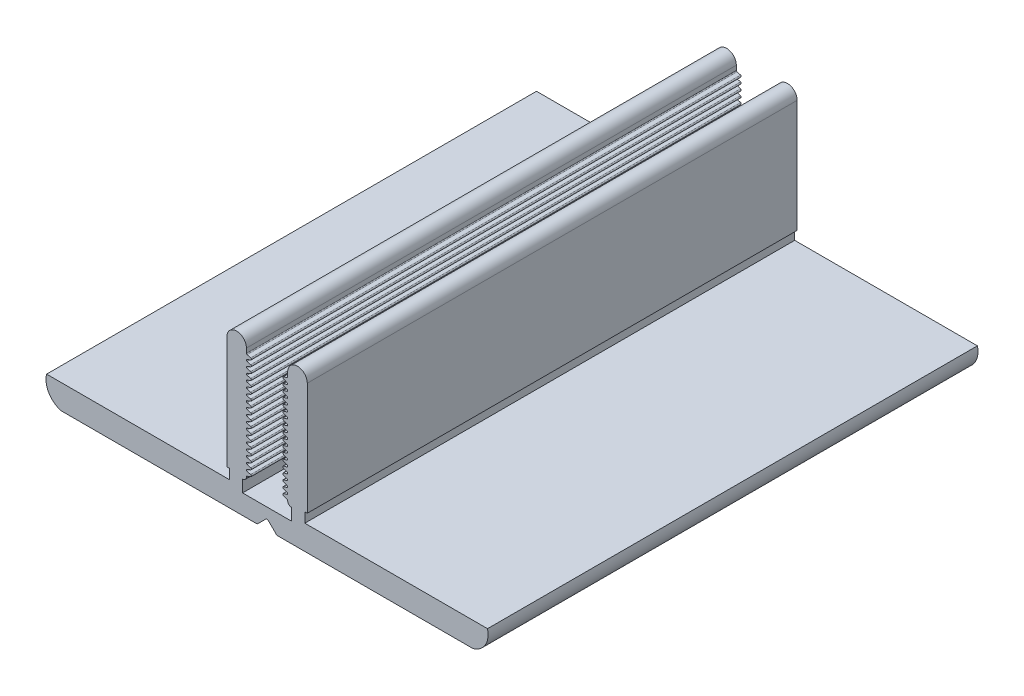
from build123d import *

# Parameters (mm, degrees)
EXTRUDE_2_DEPTH = 50


with BuildPart() as part:
    # Эскиз1 → Бобышка-Вытянуть2 (new body)
    with BuildSketch(Plane.XY):
        with BuildLine():
            Line((1.597541413, 2), (6.597450249, 2))
            Line((6.597450249, 2), (6.597450249, 3.219999818))
            ThreePointArc((6.597450249, 3.219999818), (6.318034469, 3.335737623), (6.202296664, 3.615153403))
            ThreePointArc((6.202296664, 3.615153403), (6.182496578, 3.671854652), (6.134631097, 3.708130963))
            Line((6.134631097, 3.708130963), (5.765036477, 3.845297648))
            ThreePointArc((5.765036477, 3.845297648), (5.699928757, 3.943484301), (5.77348091, 4.035515354))
            Line((5.77348091, 4.035515354), (6.128891922, 4.132594707))
            ThreePointArc((6.128891922, 4.132594707), (6.179848514, 4.165627509), (6.202296664, 4.222052865))
            ThreePointArc((6.202296664, 4.222052865), (6.182496578, 4.278754114), (6.134631097, 4.315030426))
            Line((6.134631097, 4.315030426), (5.765036477, 4.45219711))
            ThreePointArc((5.765036477, 4.45219711), (5.699928757, 4.550383763), (5.77348091, 4.642414817))
            Line((5.77348091, 4.642414817), (6.128891922, 4.739494169))
            ThreePointArc((6.128891922, 4.739494169), (6.179848514, 4.772526971), (6.202296664, 4.828952328))
            ThreePointArc((6.202296664, 4.828952328), (6.182496578, 4.885653577), (6.134631097, 4.921929888))
            Line((6.134631097, 4.921929888), (5.765036477, 5.059096573))
            ThreePointArc((5.765036477, 5.059096573), (5.699928757, 5.157283226), (5.77348091, 5.249314279))
            Line((5.77348091, 5.249314279), (6.128891922, 5.346393632))
            ThreePointArc((6.128891922, 5.346393632), (6.179848514, 5.379426434), (6.202296664, 5.43585179))
            ThreePointArc((6.202296664, 5.43585179), (6.182496578, 5.492553039), (6.134631097, 5.528829351))
            Line((6.134631097, 5.528829351), (5.765036477, 5.665996035))
            ThreePointArc((5.765036477, 5.665996035), (5.699928757, 5.764182688), (5.77348091, 5.856213742))
            Line((5.77348091, 5.856213742), (6.128891922, 5.953293094))
            ThreePointArc((6.128891922, 5.953293094), (6.179848514, 5.986325896), (6.202296664, 6.042751253))
            ThreePointArc((6.202296664, 6.042751253), (6.182496578, 6.099452502), (6.134631097, 6.135728813))
            Line((6.134631097, 6.135728813), (5.765036477, 6.272895498))
            ThreePointArc((5.765036477, 6.272895498), (5.699928757, 6.37108215), (5.77348091, 6.463113204))
            Line((5.77348091, 6.463113204), (6.128891922, 6.560192556))
            ThreePointArc((6.128891922, 6.560192556), (6.179848514, 6.593225359), (6.202296664, 6.649650715))
            ThreePointArc((6.202296664, 6.649650715), (6.182496578, 6.706351964), (6.134631097, 6.742628276))
            Line((6.134631097, 6.742628276), (5.765036477, 6.87979496))
            ThreePointArc((5.765036477, 6.87979496), (5.699928757, 6.977981613), (5.77348091, 7.070012667))
            Line((5.77348091, 7.070012667), (6.128891922, 7.167092019))
            ThreePointArc((6.128891922, 7.167092019), (6.179848514, 7.200124821), (6.202296664, 7.256550178))
            ThreePointArc((6.202296664, 7.256550178), (6.182496578, 7.313251427), (6.134631097, 7.349527738))
            Line((6.134631097, 7.349527738), (5.765036477, 7.486694423))
            ThreePointArc((5.765036477, 7.486694423), (5.699928757, 7.584881075), (5.77348091, 7.676912129))
            Line((5.77348091, 7.676912129), (6.128891922, 7.773991481))
            ThreePointArc((6.128891922, 7.773991481), (6.179848514, 7.807024284), (6.202296664, 7.86344964))
            ThreePointArc((6.202296664, 7.86344964), (6.182496578, 7.920150889), (6.134631097, 7.956427201))
            Line((6.134631097, 7.956427201), (5.765036477, 8.093593885))
            ThreePointArc((5.765036477, 8.093593885), (5.699928757, 8.191780538), (5.77348091, 8.283811592))
            Line((5.77348091, 8.283811592), (6.128891922, 8.380890944))
            ThreePointArc((6.128891922, 8.380890944), (6.179848514, 8.413923746), (6.202296664, 8.470349103))
            ThreePointArc((6.202296664, 8.470349103), (6.182496578, 8.527050352), (6.134631097, 8.563326663))
            Line((6.134631097, 8.563326663), (5.765036477, 8.700493348))
            ThreePointArc((5.765036477, 8.700493348), (5.699928757, 8.79868), (5.77348091, 8.890711054))
            Line((5.77348091, 8.890711054), (6.128891922, 8.987790406))
            ThreePointArc((6.128891922, 8.987790406), (6.179848514, 9.020823209), (6.202296664, 9.077248565))
            ThreePointArc((6.202296664, 9.077248565), (6.182496578, 9.133949814), (6.134631097, 9.170226126))
            Line((6.134631097, 9.170226126), (5.765036477, 9.30739281))
            ThreePointArc((5.765036477, 9.30739281), (5.699928757, 9.405579463), (5.77348091, 9.497610517))
            Line((5.77348091, 9.497610517), (6.128891922, 9.594689869))
            ThreePointArc((6.128891922, 9.594689869), (6.179848514, 9.627722671), (6.202296664, 9.684148028))
            ThreePointArc((6.202296664, 9.684148028), (6.182496578, 9.740849277), (6.134631097, 9.777125588))
            Line((6.134631097, 9.777125588), (5.765036477, 9.914292273))
            ThreePointArc((5.765036477, 9.914292273), (5.699928757, 10.012478925), (5.77348091, 10.104509979))
            Line((5.77348091, 10.104509979), (6.128891922, 10.201589331))
            ThreePointArc((6.128891922, 10.201589331), (6.179848514, 10.234622134), (6.202296664, 10.29104749))
            ThreePointArc((6.202296664, 10.29104749), (6.182496578, 10.347748739), (6.134631097, 10.384025051))
            Line((6.134631097, 10.384025051), (5.765036477, 10.521191735))
            ThreePointArc((5.765036477, 10.521191735), (5.699928757, 10.619378388), (5.77348091, 10.711409442))
            Line((5.77348091, 10.711409442), (6.128891922, 10.808488794))
            ThreePointArc((6.128891922, 10.808488794), (6.179848514, 10.841521596), (6.202296664, 10.897946953))
            ThreePointArc((6.202296664, 10.897946953), (6.182496578, 10.954648202), (6.134631097, 10.990924513))
            Line((6.134631097, 10.990924513), (5.765036477, 11.128091198))
            ThreePointArc((5.765036477, 11.128091198), (5.699928757, 11.22627785), (5.77348091, 11.318308904))
            Line((5.77348091, 11.318308904), (6.128891922, 11.415388256))
            ThreePointArc((6.128891922, 11.415388256), (6.179848514, 11.448421059), (6.202296664, 11.504846415))
            ThreePointArc((6.202296664, 11.504846415), (6.182496578, 11.561547664), (6.134631097, 11.597823976))
            Line((6.134631097, 11.597823976), (5.765036477, 11.73499066))
            ThreePointArc((5.765036477, 11.73499066), (5.699928757, 11.833177313), (5.77348091, 11.925208367))
            Line((5.77348091, 11.925208367), (6.128891922, 12.022287719))
            ThreePointArc((6.128891922, 12.022287719), (6.179848514, 12.055320521), (6.202296664, 12.111745877))
            ThreePointArc((6.202296664, 12.111745877), (6.182496578, 12.168447127), (6.134631097, 12.204723438))
            Line((6.134631097, 12.204723438), (5.765036477, 12.341890123))
            ThreePointArc((5.765036477, 12.341890123), (5.699928757, 12.440076775), (5.77348091, 12.532107829))
            Line((5.77348091, 12.532107829), (6.128891922, 12.629187181))
            ThreePointArc((6.128891922, 12.629187181), (6.179848514, 12.662219984), (6.202296664, 12.71864534))
            ThreePointArc((6.202296664, 12.71864534), (6.182496578, 12.775346589), (6.134631097, 12.811622901))
            Line((6.134631097, 12.811622901), (5.765036477, 12.948789585))
            ThreePointArc((5.765036477, 12.948789585), (5.699928757, 13.046976238), (5.77348091, 13.139007291))
            Line((5.77348091, 13.139007291), (6.128891922, 13.236086644))
            ThreePointArc((6.128891922, 13.236086644), (6.179848514, 13.269119446), (6.202296664, 13.325544802))
            ThreePointArc((6.202296664, 13.325544802), (6.182496578, 13.382246052), (6.134631097, 13.418522363))
            Line((6.134631097, 13.418522363), (5.765036477, 13.555689048))
            ThreePointArc((5.765036477, 13.555689048), (5.699928757, 13.6538757), (5.77348091, 13.745906754))
            Line((5.77348091, 13.745906754), (6.128891922, 13.842986106))
            ThreePointArc((6.128891922, 13.842986106), (6.179848514, 13.876018909), (6.202296664, 13.932444265))
            ThreePointArc((6.202296664, 13.932444265), (6.182496578, 13.989145514), (6.134631097, 14.025421826))
            Line((6.134631097, 14.025421826), (5.765036477, 14.16258851))
            ThreePointArc((5.765036477, 14.16258851), (5.699928757, 14.260775163), (5.77348091, 14.352806216))
            Line((5.77348091, 14.352806216), (6.128891922, 14.449885569))
            ThreePointArc((6.128891922, 14.449885569), (6.179848514, 14.482918371), (6.202296664, 14.539343727))
            Line((6.202296664, 14.539343727), (6.202296664, 15))
            ThreePointArc((6.202296664, 15), (7.202296664, 16), (8.202296664, 15))
            Line((8.202296664, 15), (8.202296664, 3.505592298))
            Line((8.202296664, 3.505592298), (7.952296664, 3.505592298))
            Line((7.952296664, 3.505592298), (7.952296664, 2.5))
            Line((7.952296664, 2.5), (10.76426584, 2.5))
            Line((10.76426584, 2.5), (26.597495831, 2.5))
            ThreePointArc((26.597495831, 2.5), (26.365262784, 0.939339828), (25.097495831, 0))
            Line((25.097495831, 0), (17.5, 0))
            Line((17.5, 0), (5.180338543, 0))
            ThreePointArc((5.180338543, 0), (5.103801857, 0.015224093), (5.038917187, 0.058578644))
            Line((5.038917187, 0.058578644), (4.238917187, 0.858578644))
            ThreePointArc((4.238917187, 0.858578644), (4.097495831, 0.917157288), (3.956074475, 0.858578644))
            Line((3.956074475, 0.858578644), (3.156074475, 0.058578644))
            ThreePointArc((3.156074475, 0.058578644), (3.091189805, 0.015224093), (3.014653118, 0))
            Line((3.014653118, 0), (-9.305008338, 0))
            Line((-9.305008338, 0), (-16.902504169, 0))
            ThreePointArc((-16.902504169, 0), (-18.170271122, 0.939339828), (-18.402504169, 2.5))
            Line((-18.402504169, 2.5), (0.242694998, 2.5))
            Line((0.242694998, 2.5), (0.242694998, 3.505592298))
            Line((0.242694998, 3.505592298), (-0.007305002, 3.505592298))
            Line((-0.007305002, 3.505592298), (-0.007305002, 15))
            ThreePointArc((-0.007305002, 15), (0.992694998, 16), (1.992694998, 15))
            Line((1.992694998, 15), (1.992694998, 14.539343727))
            ThreePointArc((1.992694998, 14.539343727), (2.015143148, 14.482918371), (2.06609974, 14.449885569))
            Line((2.06609974, 14.449885569), (2.421510752, 14.352806216))
            ThreePointArc((2.421510752, 14.352806216), (2.495062905, 14.260775163), (2.429955184, 14.16258851))
            Line((2.429955184, 14.16258851), (2.060360565, 14.025421826))
            ThreePointArc((2.060360565, 14.025421826), (2.012495084, 13.989145514), (1.992694998, 13.932444265))
            ThreePointArc((1.992694998, 13.932444265), (2.015143148, 13.876018909), (2.06609974, 13.842986106))
            Line((2.06609974, 13.842986106), (2.421510752, 13.745906754))
            ThreePointArc((2.421510752, 13.745906754), (2.495062905, 13.6538757), (2.429955184, 13.555689048))
            Line((2.429955184, 13.555689048), (2.060360565, 13.418522363))
            ThreePointArc((2.060360565, 13.418522363), (2.012495084, 13.382246052), (1.992694998, 13.325544802))
            ThreePointArc((1.992694998, 13.325544802), (2.015143148, 13.269119446), (2.06609974, 13.236086644))
            Line((2.06609974, 13.236086644), (2.421510752, 13.139007291))
            ThreePointArc((2.421510752, 13.139007291), (2.495062905, 13.046976238), (2.429955184, 12.948789585))
            Line((2.429955184, 12.948789585), (2.060360565, 12.811622901))
            ThreePointArc((2.060360565, 12.811622901), (2.012495084, 12.775346589), (1.992694998, 12.71864534))
            ThreePointArc((1.992694998, 12.71864534), (2.015143148, 12.662219984), (2.06609974, 12.629187181))
            Line((2.06609974, 12.629187181), (2.421510752, 12.532107829))
            ThreePointArc((2.421510752, 12.532107829), (2.495062905, 12.440076775), (2.429955184, 12.341890123))
            Line((2.429955184, 12.341890123), (2.060360565, 12.204723438))
            ThreePointArc((2.060360565, 12.204723438), (2.012495084, 12.168447127), (1.992694998, 12.111745877))
            ThreePointArc((1.992694998, 12.111745877), (2.015143148, 12.055320521), (2.06609974, 12.022287719))
            Line((2.06609974, 12.022287719), (2.421510752, 11.925208367))
            ThreePointArc((2.421510752, 11.925208367), (2.495062905, 11.833177313), (2.429955184, 11.73499066))
            Line((2.429955184, 11.73499066), (2.060360565, 11.597823976))
            ThreePointArc((2.060360565, 11.597823976), (2.012495084, 11.561547664), (1.992694998, 11.504846415))
            ThreePointArc((1.992694998, 11.504846415), (2.015143148, 11.448421059), (2.06609974, 11.415388256))
            Line((2.06609974, 11.415388256), (2.421510752, 11.318308904))
            ThreePointArc((2.421510752, 11.318308904), (2.495062905, 11.22627785), (2.429955184, 11.128091198))
            Line((2.429955184, 11.128091198), (2.060360565, 10.990924513))
            ThreePointArc((2.060360565, 10.990924513), (2.012495084, 10.954648202), (1.992694998, 10.897946953))
            ThreePointArc((1.992694998, 10.897946953), (2.015143148, 10.841521596), (2.06609974, 10.808488794))
            Line((2.06609974, 10.808488794), (2.421510752, 10.711409442))
            ThreePointArc((2.421510752, 10.711409442), (2.495062905, 10.619378388), (2.429955184, 10.521191735))
            Line((2.429955184, 10.521191735), (2.060360565, 10.384025051))
            ThreePointArc((2.060360565, 10.384025051), (2.012495084, 10.347748739), (1.992694998, 10.29104749))
            ThreePointArc((1.992694998, 10.29104749), (2.015143148, 10.234622134), (2.06609974, 10.201589331))
            Line((2.06609974, 10.201589331), (2.421510752, 10.104509979))
            ThreePointArc((2.421510752, 10.104509979), (2.495062905, 10.012478925), (2.429955184, 9.914292273))
            Line((2.429955184, 9.914292273), (2.060360565, 9.777125588))
            ThreePointArc((2.060360565, 9.777125588), (2.012495084, 9.740849277), (1.992694998, 9.684148028))
            ThreePointArc((1.992694998, 9.684148028), (2.015143148, 9.627722671), (2.06609974, 9.594689869))
            Line((2.06609974, 9.594689869), (2.421510752, 9.497610517))
            ThreePointArc((2.421510752, 9.497610517), (2.495062905, 9.405579463), (2.429955184, 9.30739281))
            Line((2.429955184, 9.30739281), (2.060360565, 9.170226126))
            ThreePointArc((2.060360565, 9.170226126), (2.012495084, 9.133949814), (1.992694998, 9.077248565))
            ThreePointArc((1.992694998, 9.077248565), (2.015143148, 9.020823209), (2.06609974, 8.987790406))
            Line((2.06609974, 8.987790406), (2.421510752, 8.890711054))
            ThreePointArc((2.421510752, 8.890711054), (2.495062905, 8.79868), (2.429955184, 8.700493348))
            Line((2.429955184, 8.700493348), (2.060360565, 8.563326663))
            ThreePointArc((2.060360565, 8.563326663), (2.012495084, 8.527050352), (1.992694998, 8.470349103))
            ThreePointArc((1.992694998, 8.470349103), (2.015143148, 8.413923746), (2.06609974, 8.380890944))
            Line((2.06609974, 8.380890944), (2.421510752, 8.283811592))
            ThreePointArc((2.421510752, 8.283811592), (2.495062905, 8.191780538), (2.429955184, 8.093593885))
            Line((2.429955184, 8.093593885), (2.060360565, 7.956427201))
            ThreePointArc((2.060360565, 7.956427201), (2.012495084, 7.920150889), (1.992694998, 7.86344964))
            ThreePointArc((1.992694998, 7.86344964), (2.015143148, 7.807024284), (2.06609974, 7.773991481))
            Line((2.06609974, 7.773991481), (2.421510752, 7.676912129))
            ThreePointArc((2.421510752, 7.676912129), (2.495062905, 7.584881075), (2.429955184, 7.486694423))
            Line((2.429955184, 7.486694423), (2.060360565, 7.349527738))
            ThreePointArc((2.060360565, 7.349527738), (2.012495084, 7.313251427), (1.992694998, 7.256550178))
            ThreePointArc((1.992694998, 7.256550178), (2.015143148, 7.200124821), (2.06609974, 7.167092019))
            Line((2.06609974, 7.167092019), (2.421510752, 7.070012667))
            ThreePointArc((2.421510752, 7.070012667), (2.495062905, 6.977981613), (2.429955184, 6.87979496))
            Line((2.429955184, 6.87979496), (2.060360565, 6.742628276))
            ThreePointArc((2.060360565, 6.742628276), (2.012495084, 6.706351964), (1.992694998, 6.649650715))
            ThreePointArc((1.992694998, 6.649650715), (2.015143148, 6.593225359), (2.06609974, 6.560192556))
            Line((2.06609974, 6.560192556), (2.421510752, 6.463113204))
            ThreePointArc((2.421510752, 6.463113204), (2.495062905, 6.37108215), (2.429955184, 6.272895498))
            Line((2.429955184, 6.272895498), (2.060360565, 6.135728813))
            ThreePointArc((2.060360565, 6.135728813), (2.012495084, 6.099452502), (1.992694998, 6.042751253))
            ThreePointArc((1.992694998, 6.042751253), (2.015143148, 5.986325896), (2.06609974, 5.953293094))
            Line((2.06609974, 5.953293094), (2.421510752, 5.856213742))
            ThreePointArc((2.421510752, 5.856213742), (2.495062905, 5.764182688), (2.429955184, 5.665996035))
            Line((2.429955184, 5.665996035), (2.060360565, 5.528829351))
            ThreePointArc((2.060360565, 5.528829351), (2.012495084, 5.492553039), (1.992694998, 5.43585179))
            ThreePointArc((1.992694998, 5.43585179), (2.015143148, 5.379426434), (2.06609974, 5.346393632))
            Line((2.06609974, 5.346393632), (2.421510752, 5.249314279))
            ThreePointArc((2.421510752, 5.249314279), (2.495062905, 5.157283226), (2.429955184, 5.059096573))
            Line((2.429955184, 5.059096573), (2.060360565, 4.921929888))
            ThreePointArc((2.060360565, 4.921929888), (2.012495084, 4.885653577), (1.992694998, 4.828952328))
            ThreePointArc((1.992694998, 4.828952328), (2.015143148, 4.772526971), (2.06609974, 4.739494169))
            Line((2.06609974, 4.739494169), (2.421510752, 4.642414817))
            ThreePointArc((2.421510752, 4.642414817), (2.495062905, 4.550383763), (2.429955184, 4.45219711))
            Line((2.429955184, 4.45219711), (2.060360565, 4.315030426))
            ThreePointArc((2.060360565, 4.315030426), (2.012495084, 4.278754114), (1.992694998, 4.222052865))
            ThreePointArc((1.992694998, 4.222052865), (2.015143148, 4.165627509), (2.06609974, 4.132594707))
            Line((2.06609974, 4.132594707), (2.421510752, 4.035515354))
            ThreePointArc((2.421510752, 4.035515354), (2.495062905, 3.943484301), (2.429955184, 3.845297648))
            Line((2.429955184, 3.845297648), (2.060360565, 3.708130963))
            ThreePointArc((2.060360565, 3.708130963), (2.012495084, 3.671854652), (1.992694998, 3.615153403))
            ThreePointArc((1.992694998, 3.615153403), (1.876957193, 3.335737623), (1.597541413, 3.219999818))
            Line((1.597541413, 3.219999818), (1.597541413, 2))
        make_face()
    extrude(amount=EXTRUDE_2_DEPTH)


solid = part.part
